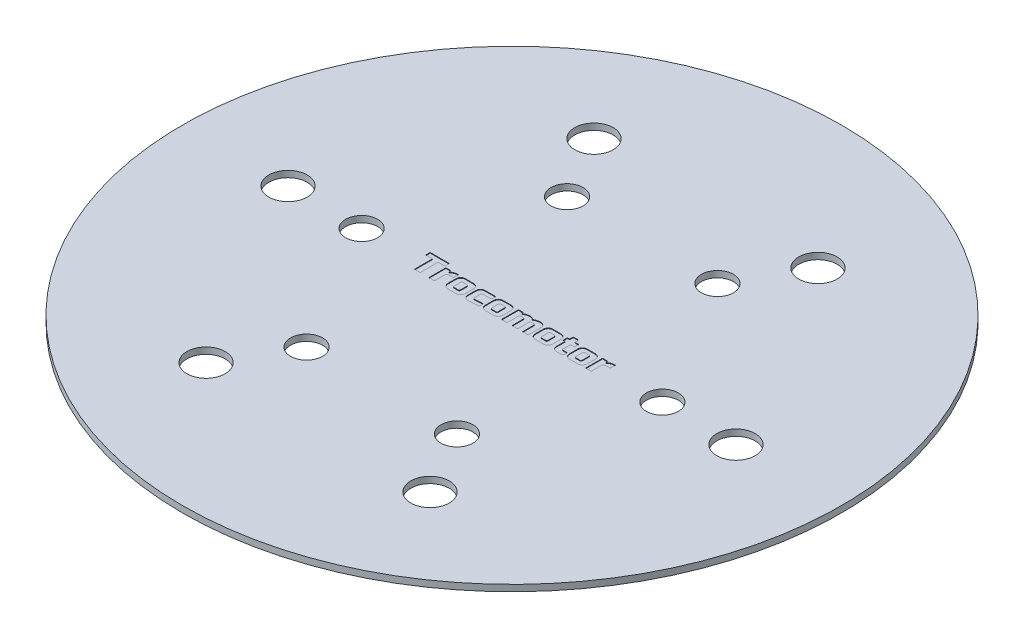
from build123d import *

# Parameters (mm, degrees)
SKETCH1_R           = 51.5
SKETCH1_R_2         = 2.5
SKETCH1_R_3         = 3
BOSS_EXTRUDE1_DEPTH = 1
CUT_EXTRUDE1_DEPTH  = 0.1


with BuildPart() as part:
    # Sketch1 → Boss-Extrude1 (new body)
    with BuildSketch(Plane(origin=(0, 0, 0), x_dir=(1, 0, 0), z_dir=(0, 1, 0))):
        Circle(SKETCH1_R)
        with Locations((23.5, 0)):
            Circle(SKETCH1_R_2, mode=Mode.SUBTRACT)
        with Locations((35, 0)):
            Circle(SKETCH1_R_3, mode=Mode.SUBTRACT)
        with Locations((11.75, -20.351596989)):
            Circle(SKETCH1_R_2, mode=Mode.SUBTRACT)
        with Locations((17.5, -30.310889132)):
            Circle(SKETCH1_R_3, mode=Mode.SUBTRACT)
        with Locations((-11.75, -20.351596989)):
            Circle(SKETCH1_R_2, mode=Mode.SUBTRACT)
        with Locations((-17.5, -30.310889132)):
            Circle(SKETCH1_R_3, mode=Mode.SUBTRACT)
        with Locations((-23.5, 0)):
            Circle(SKETCH1_R_2, mode=Mode.SUBTRACT)
        with Locations((-35, 0)):
            Circle(SKETCH1_R_3, mode=Mode.SUBTRACT)
        with Locations((-11.75, 20.351596989)):
            Circle(SKETCH1_R_2, mode=Mode.SUBTRACT)
        with Locations((-17.5, 30.310889132)):
            Circle(SKETCH1_R_3, mode=Mode.SUBTRACT)
        with Locations((11.75, 20.351596989)):
            Circle(SKETCH1_R_2, mode=Mode.SUBTRACT)
        with Locations((17.5, 30.310889132)):
            Circle(SKETCH1_R_3, mode=Mode.SUBTRACT)
    extrude(amount=BOSS_EXTRUDE1_DEPTH)

    # Sketch2 → Cut-Extrude1 (cut)
    with BuildSketch(Plane(origin=(0, 1, 0), x_dir=(1, 0, 0), z_dir=(0, 1, 0))):
        Polygon((-12.954630012, -1.385679129), (-13.854588673, -1.385679129), (-13.854588673, 1.414754934), (-14.905022737, 1.414754934), (-14.905022737, 2.114320871), (-11.904919388, 2.114320871), (-11.904919388, 1.414754934), (-12.954630012, 1.414754934), align=None)
        with BuildLine():
            add(Edge.make_bspline(
                [(-10.077511368, 0.539393215), (-10.130693873, 0.537566002), (-10.238506998, 0.533861823), (-10.400551905, 0.503611331), (-10.565590742, 0.458041721), (-10.672861917, 0.412830817), (-10.727883423, 0.389641251)],
                knots=[0, 0, 0, 0, 0.000159434, 0.00032321, 0.000493137, 0.000672078, 0.000672078, 0.000672078, 0.000672078], degree=3))
            Line((-10.727883423, 0.389641251), (-10.727883423, -1.385679129))
            Line((-10.727883423, -1.385679129), (-11.602521703, -1.385679129))
            Line((-11.602521703, -1.385679129), (-11.602521703, 1.264279531))
            Line((-11.602521703, 1.264279531), (-10.827718065, 1.264279531))
            Line((-10.827718065, 1.264279531), (-10.777800744, 0.939455224))
            add(Edge.make_bspline(
                [(-10.777800744, 0.939455224), (-10.742009923, 0.969117056), (-10.671956487, 1.027174212), (-10.562594976, 1.10431632), (-10.451388794, 1.16895906), (-10.339261666, 1.222267312), (-10.225439803, 1.262811854), (-10.110859676, 1.29300493), (-9.99463304, 1.310777818), (-9.916724856, 1.313058566), (-9.877842084, 1.314196853)],
                knots=[0, 0, 0, 0, 0.000139421, 0.000272889, 0.00040094, 0.000524887, 0.000644795, 0.000762884, 0.000879929, 0.000996547, 0.000996547, 0.000996547, 0.000996547], degree=3))
            Line((-9.877842084, 1.314196853), (-9.652852418, 1.314196853))
            Line((-9.652852418, 1.314196853), (-9.652852418, 0.539393215))
            Line((-9.652852418, 0.539393215), (-10.077511368, 0.539393215))
        make_face()
        with BuildLine():
            add(Edge.make_bspline(
                [(-6.58763952, -0.635472432), (-6.58843321, -0.665877006), (-6.589980361, -0.725145132), (-6.599153994, -0.811881154), (-6.61580641, -0.893446584), (-6.63871088, -0.970256817), (-6.669577439, -1.041183123), (-6.705555384, -1.107879516), (-6.749405662, -1.168803852), (-6.79939127, -1.224546338), (-6.854906859, -1.274692216), (-6.916543144, -1.317411521), (-6.982193464, -1.354548413), (-7.053568604, -1.384585808), (-7.1300668, -1.407243854), (-7.211578231, -1.424176329), (-7.29809406, -1.433236808), (-7.357360057, -1.434796386), (-7.387763539, -1.43559645)],
                knots=[0, 0, 0, 0, 9.1225e-05, 0.000177827, 0.000261251, 0.000340662, 0.000417796, 0.000492911, 0.000567591, 0.000642389, 0.000717187, 0.000791448, 0.000866915, 0.0009431, 0.001023202, 0.001105918, 0.00119252, 0.001283745, 0.001283745, 0.001283745, 0.001283745], degree=3))
            Line((-7.387763539, -1.43559645), (-8.538032245, -1.43559645))
            add(Edge.make_bspline(
                [(-8.538032245, -1.43559645), (-8.56843671, -1.434799347), (-8.627704625, -1.433245542), (-8.714206834, -1.424144063), (-8.795540349, -1.407404064), (-8.87186707, -1.384263502), (-8.943449151, -1.354759941), (-9.009241677, -1.317384773), (-9.070893172, -1.274699913), (-9.126398446, -1.224542302), (-9.176410106, -1.168812264), (-9.22016647, -1.10784988), (-9.256453857, -1.041377969), (-9.285953016, -0.969931033), (-9.310293942, -0.893622824), (-9.326551561, -0.811851075), (-9.33583976, -0.725153246), (-9.337370826, -0.665879757), (-9.338156263, -0.635472432)],
                knots=[0, 0, 0, 0, 9.1225e-05, 0.000177827, 0.000260543, 0.000339953, 0.000416805, 0.000492272, 0.000566533, 0.000641331, 0.000716129, 0.000790808, 0.000865924, 0.000942776, 0.0010224, 0.001105825, 0.001192426, 0.001283651, 0.001283651, 0.001283651, 0.001283651], degree=3))
            Line((-9.338156263, -0.635472432), (-9.338156263, 0.514796274))
            add(Edge.make_bspline(
                [(-9.338156263, 0.514796274), (-9.337365444, 0.545202603), (-9.335823889, 0.604474152), (-9.326635397, 0.69095055), (-9.310190014, 0.772445675), (-9.285929432, 0.84851499), (-9.256652947, 0.919848221), (-9.219942445, 0.98584621), (-9.176426145, 1.046686616), (-9.126435307, 1.102482477), (-9.070626124, 1.152420534), (-9.009719825, 1.196284414), (-8.943017884, 1.232255387), (-8.872095684, 1.263136614), (-8.795501113, 1.285919479), (-8.714218017, 1.302768687), (-8.627701598, 1.311839388), (-8.568435683, 1.313397527), (-8.538032245, 1.314196853)],
                knots=[0, 0, 0, 0, 9.1225e-05, 0.000177827, 0.000260543, 0.000340167, 0.000417019, 0.000491501, 0.00056618, 0.000640979, 0.000715777, 0.000790456, 0.000865572, 0.000942705, 0.001022116, 0.001104832, 0.001191433, 0.001282659, 0.001282659, 0.001282659, 0.001282659], degree=3))
            Line((-8.538032245, 1.314196853), (-7.387763539, 1.314196853))
            add(Edge.make_bspline(
                [(-7.387763539, 1.314196853), (-7.357361097, 1.313394553), (-7.298097126, 1.311830616), (-7.211566904, 1.302801096), (-7.130106685, 1.285758462), (-7.053336365, 1.263462871), (-6.982625101, 1.232046402), (-6.916064377, 1.196311943), (-6.855174078, 1.152412636), (-6.799354363, 1.102486563), (-6.749389652, 1.046678183), (-6.705779604, 0.985875776), (-6.669375331, 0.919654656), (-6.638733759, 0.848841037), (-6.615907263, 0.772270432), (-6.599070431, 0.690980538), (-6.589996242, 0.604466035), (-6.588438594, 0.545199851), (-6.58763952, 0.514796274)],
                knots=[0, 0, 0, 0, 9.1225e-05, 0.000177827, 0.000260543, 0.000340645, 0.000417115, 0.000492231, 0.00056691, 0.000641708, 0.000716506, 0.000791185, 0.000865668, 0.000942802, 0.001022212, 0.001104928, 0.00119153, 0.001282755, 0.001282755, 0.001282755, 0.001282755], degree=3))
            Line((-6.58763952, 0.514796274), (-6.58763952, -0.635472432))
        make_face()
        with BuildLine():
            add(Edge.make_bspline(
                [(-7.46300124, 0.439558572), (-7.463429228, 0.455280053), (-7.464235033, 0.484880114), (-7.473503581, 0.526297296), (-7.489794119, 0.561151975), (-7.511693524, 0.590535573), (-7.541077123, 0.612434979), (-7.575931801, 0.628725516), (-7.617348984, 0.637994065), (-7.646949044, 0.63879987), (-7.662670525, 0.639227857)],
                knots=[0, 0, 0, 0, 4.7113e-05, 8.8702e-05, 0.000126245, 0.000161841, 0.000197436, 0.000234979, 0.000276569, 0.000323681, 0.000323681, 0.000323681, 0.000323681], degree=3))
            Line((-7.662670525, 0.639227857), (-8.262401819, 0.639227857))
            add(Edge.make_bspline(
                [(-8.262401819, 0.639227857), (-8.278129265, 0.638812972), (-8.307740558, 0.638031836), (-8.349298406, 0.628551044), (-8.384578016, 0.612647939), (-8.414092727, 0.590514628), (-8.436004364, 0.561157906), (-8.452291381, 0.52629549), (-8.461560998, 0.484880658), (-8.462366642, 0.455280242), (-8.462794543, 0.439558572)],
                knots=[0, 0, 0, 0, 4.7113e-05, 8.8702e-05, 0.000126901, 0.000162497, 0.000198093, 0.000235635, 0.000277225, 0.000324338, 0.000324338, 0.000324338, 0.000324338], degree=3))
            Line((-8.462794543, 0.439558572), (-8.462794543, -0.56095817))
            add(Edge.make_bspline(
                [(-8.462794543, -0.56095817), (-8.462366642, -0.576679839), (-8.461560998, -0.606280255), (-8.452291381, -0.647695088), (-8.436004364, -0.682557504), (-8.414092727, -0.711914226), (-8.384578016, -0.734047536), (-8.349298406, -0.749950642), (-8.307740558, -0.759431433), (-8.278129265, -0.76021257), (-8.262401819, -0.760627455)],
                knots=[0, 0, 0, 0, 4.7113e-05, 8.8702e-05, 0.000126245, 0.000161841, 0.000197436, 0.000235635, 0.000277225, 0.000324338, 0.000324338, 0.000324338, 0.000324338], degree=3))
            Line((-8.262401819, -0.760627455), (-7.662670525, -0.760627455))
            add(Edge.make_bspline(
                [(-7.662670525, -0.760627455), (-7.646949044, -0.760199468), (-7.617348984, -0.759393662), (-7.575931801, -0.750125114), (-7.541077123, -0.733834577), (-7.511693524, -0.711935171), (-7.489794119, -0.682551572), (-7.473503581, -0.647696894), (-7.464235033, -0.606279712), (-7.463429228, -0.576679651), (-7.46300124, -0.56095817)],
                knots=[0, 0, 0, 0, 4.7113e-05, 8.8702e-05, 0.000126245, 0.000161841, 0.000197436, 0.000234979, 0.000276569, 0.000323681, 0.000323681, 0.000323681, 0.000323681], degree=3))
            Line((-7.46300124, -0.56095817), (-7.46300124, 0.439558572))
        make_face(mode=Mode.SUBTRACT)
        with BuildLine():
            add(Edge.make_bspline(
                [(-3.789375775, -1.335761808), (-3.866044014, -1.343648372), (-4.01713998, -1.359191026), (-4.24047292, -1.379213492), (-4.456983717, -1.397085946), (-4.66686896, -1.410148179), (-4.869844696, -1.422725584), (-5.065983898, -1.429028655), (-5.255028702, -1.434982607), (-5.37876737, -1.435394266), (-5.439541133, -1.43559645)],
                knots=[0, 0, 0, 0, 0.000231216, 0.000455674, 0.000672678, 0.000882926, 0.001086541, 0.001282727, 0.001471612, 0.001653925, 0.001653925, 0.001653925, 0.001653925], degree=3))
            add(Edge.make_bspline(
                [(-5.439541133, -1.43559645), (-5.467313429, -1.435223467), (-5.521369864, -1.434497486), (-5.600170365, -1.423544274), (-5.674895653, -1.408175024), (-5.745648205, -1.385492014), (-5.8120532, -1.356668419), (-5.874640406, -1.32163434), (-5.932209609, -1.279389197), (-5.986086013, -1.231934634), (-6.033540576, -1.17805823), (-6.075785719, -1.120489027), (-6.110819798, -1.057901821), (-6.139643393, -0.991496826), (-6.162326403, -0.920744273), (-6.177695653, -0.846018986), (-6.188648865, -0.767218485), (-6.189374846, -0.71316205), (-6.18974783, -0.685389753)],
                knots=[0, 0, 0, 0, 8.3246e-05, 0.000162031, 0.000238226, 0.000311896, 0.000384471, 0.000455091, 0.000526576, 0.00059831, 0.000670044, 0.000741529, 0.000812148, 0.000884723, 0.000958394, 0.001034589, 0.001113374, 0.00119662, 0.00119662, 0.00119662, 0.00119662], degree=3))
            Line((-6.18974783, -0.685389753), (-6.18974783, 0.464155513))
            add(Edge.make_bspline(
                [(-6.18974783, 0.464155513), (-6.188953739, 0.494560682), (-6.187405804, 0.55382997), (-6.178262621, 0.640322431), (-6.161610275, 0.721986382), (-6.137882012, 0.798256021), (-6.107832642, 0.869490303), (-6.071789052, 0.935825372), (-6.027982366, 0.996750953), (-5.978036351, 1.052570074), (-5.922215157, 1.102501898), (-5.861312074, 1.146367447), (-5.794609262, 1.182337968), (-5.723687304, 1.21321932), (-5.647092664, 1.23600215), (-5.565809588, 1.252851368), (-5.479293164, 1.261922066), (-5.42002725, 1.263480205), (-5.389623811, 1.264279531)],
                knots=[0, 0, 0, 0, 9.1225e-05, 0.000177827, 0.000260543, 0.000340857, 0.000417042, 0.000492158, 0.000566837, 0.000641635, 0.000716434, 0.000791113, 0.000866229, 0.000943362, 0.001022773, 0.001105489, 0.00119209, 0.001283315, 0.001283315, 0.001283315, 0.001283315], degree=3))
            Line((-5.389623811, 1.264279531), (-3.789375775, 1.264279531))
            Line((-3.789375775, 1.264279531), (-3.789375775, 0.589310536))
            Line((-3.789375775, 0.589310536), (-5.113993386, 0.589310536))
            add(Edge.make_bspline(
                [(-5.113993386, 0.589310536), (-5.129720832, 0.588895651), (-5.159332125, 0.588114514), (-5.200889973, 0.578633723), (-5.236169583, 0.562730617), (-5.265684294, 0.540597307), (-5.287595931, 0.511240585), (-5.303882948, 0.476378169), (-5.313152565, 0.434963336), (-5.313958208, 0.40536292), (-5.31438611, 0.389641251)],
                knots=[0, 0, 0, 0, 4.7113e-05, 8.8702e-05, 0.000126901, 0.000162497, 0.000198093, 0.000235635, 0.000277225, 0.000324338, 0.000324338, 0.000324338, 0.000324338], degree=3))
            Line((-5.31438611, 0.389641251), (-5.31438611, -0.585555111))
            add(Edge.make_bspline(
                [(-5.31438611, -0.585555111), (-5.313937086, -0.597679225), (-5.313068753, -0.621125074), (-5.30322528, -0.654708837), (-5.286856237, -0.684703361), (-5.265384233, -0.711625578), (-5.238462016, -0.733097582), (-5.208467492, -0.749466625), (-5.174883729, -0.759310098), (-5.15143788, -0.760178431), (-5.139313766, -0.760627455)],
                knots=[0, 0, 0, 0, 3.6288e-05, 7.0174e-05, 0.000103835, 0.000138295, 0.000172756, 0.000206417, 0.000240303, 0.00027659, 0.00027659, 0.00027659, 0.00027659], degree=3))
            add(Edge.make_bspline(
                [(-5.139313766, -0.760627455), (-5.099522518, -0.760268298), (-5.015103827, -0.759506333), (-4.881498927, -0.755667698), (-4.733674522, -0.749769579), (-4.572071377, -0.742029515), (-4.396307581, -0.730747546), (-4.206516125, -0.71782947), (-4.002503891, -0.702611217), (-3.861954759, -0.691254378), (-3.789375775, -0.685389753)],
                knots=[0, 0, 0, 0, 0.000119376, 0.000253261, 0.000400957, 0.000563202, 0.000738611, 0.00092932, 0.001133895, 0.001352341, 0.001352341, 0.001352341, 0.001352341], degree=3))
            Line((-3.789375775, -0.685389753), (-3.789375775, -1.335761808))
        make_face()
        with BuildLine():
            add(Edge.make_bspline(
                [(-0.70752377, -0.635472432), (-0.708317459, -0.665877006), (-0.709864611, -0.725145132), (-0.719038244, -0.811881154), (-0.735690659, -0.893446584), (-0.75859513, -0.970256817), (-0.789461689, -1.041183123), (-0.825439634, -1.107879516), (-0.869289912, -1.168803852), (-0.919275519, -1.224546338), (-0.974791109, -1.274692216), (-1.036427394, -1.317411521), (-1.102077713, -1.354548413), (-1.173452853, -1.384585808), (-1.24995105, -1.407243854), (-1.33146248, -1.424176329), (-1.417978309, -1.433236808), (-1.477244307, -1.434796386), (-1.507647788, -1.43559645)],
                knots=[0, 0, 0, 0, 9.1225e-05, 0.000177827, 0.000261251, 0.000340662, 0.000417796, 0.000492911, 0.000567591, 0.000642389, 0.000717187, 0.000791448, 0.000866915, 0.0009431, 0.001023202, 0.001105918, 0.00119252, 0.001283745, 0.001283745, 0.001283745, 0.001283745], degree=3))
            Line((-1.507647788, -1.43559645), (-2.657916494, -1.43559645))
            add(Edge.make_bspline(
                [(-2.657916494, -1.43559645), (-2.688320959, -1.434799347), (-2.747588875, -1.433245542), (-2.834091083, -1.424144063), (-2.915424599, -1.407404064), (-2.991751319, -1.384263502), (-3.0633334, -1.354759941), (-3.129125926, -1.317384773), (-3.190777421, -1.274699913), (-3.246282696, -1.224542302), (-3.296294356, -1.168812264), (-3.34005072, -1.10784988), (-3.376338107, -1.041377969), (-3.405837266, -0.969931033), (-3.430178191, -0.893622824), (-3.446435811, -0.811851075), (-3.455724009, -0.725153246), (-3.457255075, -0.665879757), (-3.458040513, -0.635472432)],
                knots=[0, 0, 0, 0, 9.1225e-05, 0.000177827, 0.000260543, 0.000339953, 0.000416805, 0.000492272, 0.000566533, 0.000641331, 0.000716129, 0.000790808, 0.000865924, 0.000942776, 0.0010224, 0.001105825, 0.001192426, 0.001283651, 0.001283651, 0.001283651, 0.001283651], degree=3))
            Line((-3.458040513, -0.635472432), (-3.458040513, 0.514796274))
            add(Edge.make_bspline(
                [(-3.458040513, 0.514796274), (-3.457249694, 0.545202603), (-3.455708138, 0.604474152), (-3.446519647, 0.69095055), (-3.430074264, 0.772445675), (-3.405813682, 0.84851499), (-3.376537196, 0.919848221), (-3.339826695, 0.98584621), (-3.296310395, 1.046686616), (-3.246319557, 1.102482477), (-3.190510374, 1.152420534), (-3.129604074, 1.196284414), (-3.062902134, 1.232255387), (-2.991979934, 1.263136614), (-2.915385362, 1.285919479), (-2.834102266, 1.302768687), (-2.747585848, 1.311839388), (-2.688319933, 1.313397527), (-2.657916494, 1.314196853)],
                knots=[0, 0, 0, 0, 9.1225e-05, 0.000177827, 0.000260543, 0.000340167, 0.000417019, 0.000491501, 0.00056618, 0.000640979, 0.000715777, 0.000790456, 0.000865572, 0.000942705, 0.001022116, 0.001104832, 0.001191433, 0.001282659, 0.001282659, 0.001282659, 0.001282659], degree=3))
            Line((-2.657916494, 1.314196853), (-1.507647788, 1.314196853))
            add(Edge.make_bspline(
                [(-1.507647788, 1.314196853), (-1.477245347, 1.313394553), (-1.417981375, 1.311830616), (-1.331451153, 1.302801096), (-1.249990935, 1.285758462), (-1.173220614, 1.263462871), (-1.102509351, 1.232046402), (-1.035948627, 1.196311943), (-0.975058327, 1.152412636), (-0.919238613, 1.102486563), (-0.869273902, 1.046678183), (-0.825663854, 0.985875776), (-0.78925958, 0.919654656), (-0.758618008, 0.848841037), (-0.735791513, 0.772270432), (-0.718954681, 0.690980538), (-0.709880492, 0.604466035), (-0.708322844, 0.545199851), (-0.70752377, 0.514796274)],
                knots=[0, 0, 0, 0, 9.1225e-05, 0.000177827, 0.000260543, 0.000340645, 0.000417115, 0.000492231, 0.00056691, 0.000641708, 0.000716506, 0.000791185, 0.000865668, 0.000942802, 0.001022212, 0.001104928, 0.00119153, 0.001282755, 0.001282755, 0.001282755, 0.001282755], degree=3))
            Line((-0.70752377, 0.514796274), (-0.70752377, -0.635472432))
        make_face()
        with BuildLine():
            add(Edge.make_bspline(
                [(-1.58288549, 0.439558572), (-1.583313477, 0.455280053), (-1.584119282, 0.484880114), (-1.593387831, 0.526297296), (-1.609678368, 0.561151975), (-1.631577774, 0.590535573), (-1.660961373, 0.612434979), (-1.695816051, 0.628725516), (-1.737233233, 0.637994065), (-1.766833294, 0.63879987), (-1.782554775, 0.639227857)],
                knots=[0, 0, 0, 0, 4.7113e-05, 8.8702e-05, 0.000126245, 0.000161841, 0.000197436, 0.000234979, 0.000276569, 0.000323681, 0.000323681, 0.000323681, 0.000323681], degree=3))
            Line((-1.782554775, 0.639227857), (-2.382286069, 0.639227857))
            add(Edge.make_bspline(
                [(-2.382286069, 0.639227857), (-2.398013515, 0.638812972), (-2.427624808, 0.638031836), (-2.469182655, 0.628551044), (-2.504462266, 0.612647939), (-2.533976977, 0.590514628), (-2.555888614, 0.561157906), (-2.57217563, 0.52629549), (-2.581445248, 0.484880658), (-2.582250891, 0.455280242), (-2.582678793, 0.439558572)],
                knots=[0, 0, 0, 0, 4.7113e-05, 8.8702e-05, 0.000126901, 0.000162497, 0.000198093, 0.000235635, 0.000277225, 0.000324338, 0.000324338, 0.000324338, 0.000324338], degree=3))
            Line((-2.582678793, 0.439558572), (-2.582678793, -0.56095817))
            add(Edge.make_bspline(
                [(-2.582678793, -0.56095817), (-2.582250891, -0.576679839), (-2.581445248, -0.606280255), (-2.57217563, -0.647695088), (-2.555888614, -0.682557504), (-2.533976977, -0.711914226), (-2.504462266, -0.734047536), (-2.469182655, -0.749950642), (-2.427624808, -0.759431433), (-2.398013515, -0.76021257), (-2.382286069, -0.760627455)],
                knots=[0, 0, 0, 0, 4.7113e-05, 8.8702e-05, 0.000126245, 0.000161841, 0.000197436, 0.000235635, 0.000277225, 0.000324338, 0.000324338, 0.000324338, 0.000324338], degree=3))
            Line((-2.382286069, -0.760627455), (-1.782554775, -0.760627455))
            add(Edge.make_bspline(
                [(-1.782554775, -0.760627455), (-1.766833294, -0.760199468), (-1.737233233, -0.759393662), (-1.695816051, -0.750125114), (-1.660961373, -0.733834577), (-1.631577774, -0.711935171), (-1.609678368, -0.682551572), (-1.593387831, -0.647696894), (-1.584119282, -0.606279712), (-1.583313477, -0.576679651), (-1.58288549, -0.56095817)],
                knots=[0, 0, 0, 0, 4.7113e-05, 8.8702e-05, 0.000126245, 0.000161841, 0.000197436, 0.000234979, 0.000276569, 0.000323681, 0.000323681, 0.000323681, 0.000323681], degree=3))
            Line((-1.58288549, -0.56095817), (-1.58288549, 0.439558572))
        make_face(mode=Mode.SUBTRACT)
        with BuildLine():
            add(Edge.make_bspline(
                [(1.515605622, 1.314196853), (1.548464751, 1.313548649), (1.612594943, 1.312283569), (1.70564259, 1.297034486), (1.79315039, 1.27425156), (1.875084969, 1.241649507), (1.950557238, 1.198409381), (2.020665339, 1.146678394), (2.085100469, 1.085591327), (2.121935924, 1.038584055), (2.140657296, 1.014692925)],
                knots=[0, 0, 0, 0, 9.8483e-05, 0.000192207, 0.000282054, 0.000369374, 0.000455876, 0.000542257, 0.000630267, 0.000721228, 0.000721228, 0.000721228, 0.000721228], degree=3))
            add(Edge.make_bspline(
                [(2.140657296, 1.014692925), (2.179322356, 1.039491577), (2.256499084, 1.088990501), (2.379200365, 1.150850937), (2.506465354, 1.202671569), (2.636783945, 1.242765959), (2.765384574, 1.274359167), (2.888621206, 1.296698473), (3.004559339, 1.311623553), (3.079640397, 1.313359545), (3.115853659, 1.314196853)],
                knots=[0, 0, 0, 0, 0.000137727, 0.000274908, 0.000411533, 0.000549505, 0.000683558, 0.000808571, 0.000925135, 0.001033738, 0.001033738, 0.001033738, 0.001033738], degree=3))
            Line((3.115853659, 1.314196853), (3.16577098, 1.314196853))
            add(Edge.make_bspline(
                [(3.16577098, 1.314196853), (3.193542764, 1.3138228), (3.247598203, 1.313094738), (3.326405793, 1.302156333), (3.401105582, 1.286733825), (3.471738199, 1.264308279), (3.53781685, 1.23483385), (3.600683217, 1.200705634), (3.657799845, 1.157742815), (3.71157139, 1.110320715), (3.759660781, 1.057210273), (3.801505395, 0.999149023), (3.836818609, 0.937019016), (3.866019634, 0.870639157), (3.888534141, 0.800059886), (3.903931696, 0.725345133), (3.914877038, 0.646541704), (3.915604125, 0.59248568), (3.915977677, 0.564713595)],
                knots=[0, 0, 0, 0, 8.3246e-05, 0.000162031, 0.000238226, 0.000311896, 0.000383808, 0.000455059, 0.00052596, 0.000597693, 0.000669911, 0.000740386, 0.000811992, 0.000883904, 0.000957574, 0.001033769, 0.001112554, 0.0011958, 0.0011958, 0.0011958, 0.0011958], degree=3))
            Line((3.915977677, 0.564713595), (3.915977677, -1.385679129))
            Line((3.915977677, -1.385679129), (3.041339396, -1.385679129))
            Line((3.041339396, -1.385679129), (3.041339396, 0.414238192))
            add(Edge.make_bspline(
                [(3.041339396, 0.414238192), (3.040893826, 0.42636505), (3.040032172, 0.449816205), (3.030141248, 0.483362267), (3.013877102, 0.513634107), (2.991586224, 0.540108005), (2.964841329, 0.56156505), (2.935080186, 0.578489015), (2.901542504, 0.587800863), (2.878135078, 0.588802624), (2.866267053, 0.589310536)],
                knots=[0, 0, 0, 0, 3.6288e-05, 7.0174e-05, 0.000103835, 0.000138755, 0.000173216, 0.000206241, 0.000240823, 0.000276389, 0.000276389, 0.000276389, 0.000276389], degree=3))
            Line((2.866267053, 0.589310536), (2.840946672, 0.589310536))
            add(Edge.make_bspline(
                [(2.840946672, 0.589310536), (2.800868528, 0.587763105), (2.715068266, 0.584450326), (2.578595831, 0.565412916), (2.426930362, 0.532901725), (2.321389418, 0.50445548), (2.265812319, 0.489475894)],
                knots=[0, 0, 0, 0, 0.000120267, 0.000257471, 0.000412692, 0.000585352, 0.000585352, 0.000585352, 0.000585352], degree=3))
            Line((2.265812319, 0.489475894), (2.265812319, -1.385679129))
            Line((2.265812319, -1.385679129), (1.391174039, -1.385679129))
            Line((1.391174039, -1.385679129), (1.391174039, 0.414238192))
            add(Edge.make_bspline(
                [(1.391174039, 0.414238192), (1.390728468, 0.42636505), (1.389866815, 0.449816205), (1.379975891, 0.483362267), (1.363711745, 0.513634107), (1.341420867, 0.540108005), (1.314675971, 0.56156505), (1.284914829, 0.578489015), (1.251377146, 0.587800863), (1.22796972, 0.588802624), (1.216101695, 0.589310536)],
                knots=[0, 0, 0, 0, 3.6288e-05, 7.0174e-05, 0.000103835, 0.000138755, 0.000173216, 0.000206241, 0.000240823, 0.000276389, 0.000276389, 0.000276389, 0.000276389], degree=3))
            Line((1.216101695, 0.589310536), (1.190781315, 0.589310536))
            add(Edge.make_bspline(
                [(1.190781315, 0.589310536), (1.15070317, 0.587763105), (1.064902908, 0.584450326), (0.928430474, 0.565412916), (0.776765004, 0.532901725), (0.67122406, 0.50445548), (0.615646962, 0.489475894)],
                knots=[0, 0, 0, 0, 0.000120267, 0.000257471, 0.000412692, 0.000585352, 0.000585352, 0.000585352, 0.000585352], degree=3))
            Line((0.615646962, 0.489475894), (0.615646962, -1.385679129))
            Line((0.615646962, -1.385679129), (-0.258991319, -1.385679129))
            Line((-0.258991319, -1.385679129), (-0.258991319, 1.264279531))
            Line((-0.258991319, 1.264279531), (0.515812319, 1.264279531))
            Line((0.515812319, 1.264279531), (0.56572964, 1.014692925))
            add(Edge.make_bspline(
                [(0.56572964, 1.014692925), (0.604957911, 1.039349273), (0.682185809, 1.087889722), (0.802172653, 1.150505671), (0.923975006, 1.201992828), (1.045730905, 1.242323386), (1.162964417, 1.274000117), (1.272428652, 1.296387495), (1.372188511, 1.311441521), (1.435740472, 1.313314325), (1.465688301, 1.314196853)],
                knots=[0, 0, 0, 0, 0.000138961, 0.000273569, 0.000405515, 0.000535229, 0.000658069, 0.000769586, 0.000870363, 0.000960174, 0.000960174, 0.000960174, 0.000960174], degree=3))
            Line((1.465688301, 1.314196853), (1.515605622, 1.314196853))
        make_face()
        with BuildLine():
            add(Edge.make_bspline(
                [(7.070897065, -0.635472432), (7.070103376, -0.665877006), (7.068556224, -0.725145132), (7.059382591, -0.811881154), (7.042730176, -0.893446584), (7.019825705, -0.970256817), (6.988959146, -1.041183123), (6.952981201, -1.107879516), (6.909130923, -1.168803852), (6.859145316, -1.224546338), (6.803629726, -1.274692216), (6.741993441, -1.317411521), (6.676343122, -1.354548413), (6.604967982, -1.384585808), (6.528469785, -1.407243854), (6.446958355, -1.424176329), (6.360442526, -1.433236808), (6.301176528, -1.434796386), (6.270773047, -1.43559645)],
                knots=[0, 0, 0, 0, 9.1225e-05, 0.000177827, 0.000261251, 0.000340662, 0.000417796, 0.000492911, 0.000567591, 0.000642389, 0.000717187, 0.000791448, 0.000866915, 0.0009431, 0.001023202, 0.001105918, 0.00119252, 0.001283745, 0.001283745, 0.001283745, 0.001283745], degree=3))
            Line((6.270773047, -1.43559645), (5.120504341, -1.43559645))
            add(Edge.make_bspline(
                [(5.120504341, -1.43559645), (5.090099876, -1.434799347), (5.030831961, -1.433245542), (4.944329752, -1.424144063), (4.862996236, -1.407404064), (4.786669516, -1.384263502), (4.715087435, -1.354759941), (4.649294909, -1.317384773), (4.587643414, -1.274699913), (4.532138139, -1.224542302), (4.482126479, -1.168812264), (4.438370115, -1.10784988), (4.402082728, -1.041377969), (4.372583569, -0.969931033), (4.348242644, -0.893622824), (4.331985024, -0.811851075), (4.322696826, -0.725153246), (4.32116576, -0.665879757), (4.320380322, -0.635472432)],
                knots=[0, 0, 0, 0, 9.1225e-05, 0.000177827, 0.000260543, 0.000339953, 0.000416805, 0.000492272, 0.000566533, 0.000641331, 0.000716129, 0.000790808, 0.000865924, 0.000942776, 0.0010224, 0.001105825, 0.001192426, 0.001283651, 0.001283651, 0.001283651, 0.001283651], degree=3))
            Line((4.320380322, -0.635472432), (4.320380322, 0.514796274))
            add(Edge.make_bspline(
                [(4.320380322, 0.514796274), (4.321171141, 0.545202603), (4.322712697, 0.604474152), (4.331901188, 0.69095055), (4.348346571, 0.772445675), (4.372607154, 0.84851499), (4.401883639, 0.919848221), (4.438594141, 0.98584621), (4.48211044, 1.046686616), (4.532101278, 1.102482477), (4.587910461, 1.152420534), (4.648816761, 1.196284414), (4.715518702, 1.232255387), (4.786440901, 1.263136614), (4.863035473, 1.285919479), (4.944318569, 1.302768687), (5.030834987, 1.311839388), (5.090100902, 1.313397527), (5.120504341, 1.314196853)],
                knots=[0, 0, 0, 0, 9.1225e-05, 0.000177827, 0.000260543, 0.000340167, 0.000417019, 0.000491501, 0.00056618, 0.000640979, 0.000715777, 0.000790456, 0.000865572, 0.000942705, 0.001022116, 0.001104832, 0.001191433, 0.001282659, 0.001282659, 0.001282659, 0.001282659], degree=3))
            Line((5.120504341, 1.314196853), (6.270773047, 1.314196853))
            add(Edge.make_bspline(
                [(6.270773047, 1.314196853), (6.301175489, 1.313394553), (6.36043946, 1.311830616), (6.446969682, 1.302801096), (6.5284299, 1.285758462), (6.605200221, 1.263462871), (6.675911484, 1.232046402), (6.742472208, 1.196311943), (6.803362508, 1.152412636), (6.859182222, 1.102486563), (6.909146933, 1.046678183), (6.952756981, 0.985875776), (6.989161255, 0.919654656), (7.019802827, 0.848841037), (7.042629322, 0.772270432), (7.059466154, 0.690980538), (7.068540343, 0.604466035), (7.070097991, 0.545199851), (7.070897065, 0.514796274)],
                knots=[0, 0, 0, 0, 9.1225e-05, 0.000177827, 0.000260543, 0.000340645, 0.000417115, 0.000492231, 0.00056691, 0.000641708, 0.000716506, 0.000791185, 0.000865668, 0.000942802, 0.001022212, 0.001104928, 0.00119153, 0.001282755, 0.001282755, 0.001282755, 0.001282755], degree=3))
            Line((7.070897065, 0.514796274), (7.070897065, -0.635472432))
        make_face()
        with BuildLine():
            add(Edge.make_bspline(
                [(6.195535345, 0.439558572), (6.195107358, 0.455280053), (6.194301553, 0.484880114), (6.185033004, 0.526297296), (6.168742467, 0.561151975), (6.146843061, 0.590535573), (6.117459463, 0.612434979), (6.082604784, 0.628725516), (6.041187602, 0.637994065), (6.011587541, 0.63879987), (5.99586606, 0.639227857)],
                knots=[0, 0, 0, 0, 4.7113e-05, 8.8702e-05, 0.000126245, 0.000161841, 0.000197436, 0.000234979, 0.000276569, 0.000323681, 0.000323681, 0.000323681, 0.000323681], degree=3))
            Line((5.99586606, 0.639227857), (5.396134766, 0.639227857))
            add(Edge.make_bspline(
                [(5.396134766, 0.639227857), (5.38040732, 0.638812972), (5.350796027, 0.638031836), (5.30923818, 0.628551044), (5.273958569, 0.612647939), (5.244443858, 0.590514628), (5.222532221, 0.561157906), (5.206245205, 0.52629549), (5.196975587, 0.484880658), (5.196169944, 0.455280242), (5.195742042, 0.439558572)],
                knots=[0, 0, 0, 0, 4.7113e-05, 8.8702e-05, 0.000126901, 0.000162497, 0.000198093, 0.000235635, 0.000277225, 0.000324338, 0.000324338, 0.000324338, 0.000324338], degree=3))
            Line((5.195742042, 0.439558572), (5.195742042, -0.56095817))
            add(Edge.make_bspline(
                [(5.195742042, -0.56095817), (5.196169944, -0.576679839), (5.196975587, -0.606280255), (5.206245205, -0.647695088), (5.222532221, -0.682557504), (5.244443858, -0.711914226), (5.273958569, -0.734047536), (5.30923818, -0.749950642), (5.350796027, -0.759431433), (5.38040732, -0.76021257), (5.396134766, -0.760627455)],
                knots=[0, 0, 0, 0, 4.7113e-05, 8.8702e-05, 0.000126245, 0.000161841, 0.000197436, 0.000235635, 0.000277225, 0.000324338, 0.000324338, 0.000324338, 0.000324338], degree=3))
            Line((5.396134766, -0.760627455), (5.99586606, -0.760627455))
            add(Edge.make_bspline(
                [(5.99586606, -0.760627455), (6.011587541, -0.760199468), (6.041187602, -0.759393662), (6.082604784, -0.750125114), (6.117459463, -0.733834577), (6.146843061, -0.711935171), (6.168742467, -0.682551572), (6.185033004, -0.647696894), (6.194301553, -0.606279712), (6.195107358, -0.576679651), (6.195535345, -0.56095817)],
                knots=[0, 0, 0, 0, 4.7113e-05, 8.8702e-05, 0.000126245, 0.000161841, 0.000197436, 0.000234979, 0.000276569, 0.000323681, 0.000323681, 0.000323681, 0.000323681], degree=3))
            Line((6.195535345, -0.56095817), (6.195535345, 0.439558572))
        make_face(mode=Mode.SUBTRACT)
        with BuildLine():
            add(Edge.make_bspline(
                [(9.369264159, -1.385679129), (9.288994618, -1.393301516), (9.12932368, -1.40846385), (8.89051446, -1.424214976), (8.654108328, -1.434049539), (8.497287911, -1.435083056), (8.419388177, -1.43559645)],
                knots=[0, 0, 0, 0, 0.000241881, 0.000481146, 0.000717897, 0.000951586, 0.000951586, 0.000951586, 0.000951586], degree=3))
            add(Edge.make_bspline(
                [(8.419388177, -1.43559645), (8.39161588, -1.435223467), (8.337559445, -1.434497486), (8.258758945, -1.423544274), (8.184033657, -1.408175024), (8.113281104, -1.385492014), (8.046876109, -1.356668419), (7.984288903, -1.32163434), (7.9267197, -1.279389197), (7.872843297, -1.231934634), (7.825388734, -1.17805823), (7.783143591, -1.120489027), (7.748109511, -1.057901821), (7.719285916, -0.991496826), (7.696602907, -0.920744273), (7.681233657, -0.846018986), (7.670280444, -0.767218485), (7.669554463, -0.71316205), (7.66918148, -0.685389753)],
                knots=[0, 0, 0, 0, 8.3246e-05, 0.000162031, 0.000238226, 0.000311896, 0.000384471, 0.000455091, 0.000526576, 0.00059831, 0.000670044, 0.000741529, 0.000812148, 0.000884723, 0.000958394, 0.001034589, 0.001113374, 0.00119662, 0.00119662, 0.00119662, 0.00119662], degree=3))
            Line((7.66918148, -0.685389753), (7.66918148, 0.589310536))
            Line((7.66918148, 0.589310536), (7.368954113, 0.589310536))
            Line((7.368954113, 0.589310536), (7.368954113, 1.264279531))
            Line((7.368954113, 1.264279531), (7.66918148, 1.264279531))
            Line((7.66918148, 1.264279531), (7.769016122, 1.864734265))
            Line((7.769016122, 1.864734265), (8.5445432, 1.864734265))
            Line((8.5445432, 1.864734265), (8.5445432, 1.264279531))
            Line((8.5445432, 1.264279531), (9.169594874, 1.264279531))
            Line((9.169594874, 1.264279531), (9.169594874, 0.589310536))
            Line((9.169594874, 0.589310536), (8.5445432, 0.589310536))
            Line((8.5445432, 0.589310536), (8.5445432, -0.56095817))
            add(Edge.make_bspline(
                [(8.5445432, -0.56095817), (8.54501226, -0.572838798), (8.545928218, -0.59603872), (8.555704213, -0.629388247), (8.572073019, -0.659383042), (8.593545106, -0.686305168), (8.620467232, -0.707777255), (8.650462028, -0.724146062), (8.683811554, -0.733922057), (8.707011477, -0.734838015), (8.718892104, -0.735307075)],
                knots=[0, 0, 0, 0, 3.5566e-05, 6.9452e-05, 0.000103114, 0.000137574, 0.000172034, 0.000205696, 0.000239582, 0.000275148, 0.000275148, 0.000275148, 0.000275148], degree=3))
            Line((8.718892104, -0.735307075), (9.369264159, -0.735307075))
            Line((9.369264159, -0.735307075), (9.369264159, -1.385679129))
        make_face()
        with BuildLine():
            add(Edge.make_bspline(
                [(12.441711451, -0.635472432), (12.440917762, -0.665877006), (12.43937061, -0.725145132), (12.430196977, -0.811881154), (12.413544562, -0.893446584), (12.390640091, -0.970256817), (12.359773533, -1.041183123), (12.323795587, -1.107879516), (12.27994531, -1.168803852), (12.229959702, -1.224546338), (12.174444112, -1.274692216), (12.112807827, -1.317411521), (12.047157508, -1.354548413), (11.975782368, -1.384585808), (11.899284171, -1.407243854), (11.817772741, -1.424176329), (11.731256912, -1.433236808), (11.671990914, -1.434796386), (11.641587433, -1.43559645)],
                knots=[0, 0, 0, 0, 9.1225e-05, 0.000177827, 0.000261251, 0.000340662, 0.000417796, 0.000492911, 0.000567591, 0.000642389, 0.000717187, 0.000791448, 0.000866915, 0.0009431, 0.001023202, 0.001105918, 0.00119252, 0.001283745, 0.001283745, 0.001283745, 0.001283745], degree=3))
            Line((11.641587433, -1.43559645), (10.491318727, -1.43559645))
            add(Edge.make_bspline(
                [(10.491318727, -1.43559645), (10.460914262, -1.434799347), (10.401646347, -1.433245542), (10.315144138, -1.424144063), (10.233810622, -1.407404064), (10.157483902, -1.384263502), (10.085901821, -1.354759941), (10.020109295, -1.317384773), (9.9584578, -1.274699913), (9.902952525, -1.224542302), (9.852940865, -1.168812264), (9.809184501, -1.10784988), (9.772897114, -1.041377969), (9.743397955, -0.969931033), (9.71905703, -0.893622824), (9.70279941, -0.811851075), (9.693511212, -0.725153246), (9.691980146, -0.665879757), (9.691194709, -0.635472432)],
                knots=[0, 0, 0, 0, 9.1225e-05, 0.000177827, 0.000260543, 0.000339953, 0.000416805, 0.000492272, 0.000566533, 0.000641331, 0.000716129, 0.000790808, 0.000865924, 0.000942776, 0.0010224, 0.001105825, 0.001192426, 0.001283651, 0.001283651, 0.001283651, 0.001283651], degree=3))
            Line((9.691194709, -0.635472432), (9.691194709, 0.514796274))
            add(Edge.make_bspline(
                [(9.691194709, 0.514796274), (9.691985527, 0.545202603), (9.693527083, 0.604474152), (9.702715574, 0.69095055), (9.719160957, 0.772445675), (9.74342154, 0.84851499), (9.772698025, 0.919848221), (9.809408527, 0.98584621), (9.852924826, 1.046686616), (9.902915664, 1.102482477), (9.958724847, 1.152420534), (10.019631147, 1.196284414), (10.086333088, 1.232255387), (10.157255287, 1.263136614), (10.233849859, 1.285919479), (10.315132955, 1.302768687), (10.401649373, 1.311839388), (10.460915288, 1.313397527), (10.491318727, 1.314196853)],
                knots=[0, 0, 0, 0, 9.1225e-05, 0.000177827, 0.000260543, 0.000340167, 0.000417019, 0.000491501, 0.00056618, 0.000640979, 0.000715777, 0.000790456, 0.000865572, 0.000942705, 0.001022116, 0.001104832, 0.001191433, 0.001282659, 0.001282659, 0.001282659, 0.001282659], degree=3))
            Line((10.491318727, 1.314196853), (11.641587433, 1.314196853))
            add(Edge.make_bspline(
                [(11.641587433, 1.314196853), (11.671989875, 1.313394553), (11.731253846, 1.311830616), (11.817784068, 1.302801096), (11.899244286, 1.285758462), (11.976014607, 1.263462871), (12.04672587, 1.232046402), (12.113286594, 1.196311943), (12.174176894, 1.152412636), (12.229996608, 1.102486563), (12.279961319, 1.046678183), (12.323571367, 0.985875776), (12.359975641, 0.919654656), (12.390617213, 0.848841037), (12.413443708, 0.772270432), (12.43028054, 0.690980538), (12.439354729, 0.604466035), (12.440912377, 0.545199851), (12.441711451, 0.514796274)],
                knots=[0, 0, 0, 0, 9.1225e-05, 0.000177827, 0.000260543, 0.000340645, 0.000417115, 0.000492231, 0.00056691, 0.000641708, 0.000716506, 0.000791185, 0.000865668, 0.000942802, 0.001022212, 0.001104928, 0.00119153, 0.001282755, 0.001282755, 0.001282755, 0.001282755], degree=3))
            Line((12.441711451, 0.514796274), (12.441711451, -0.635472432))
        make_face()
        with BuildLine():
            add(Edge.make_bspline(
                [(11.566349731, 0.439558572), (11.565921744, 0.455280053), (11.565115939, 0.484880114), (11.555847391, 0.526297296), (11.539556853, 0.561151975), (11.517657447, 0.590535573), (11.488273849, 0.612434979), (11.45341917, 0.628725516), (11.412001988, 0.637994065), (11.382401927, 0.63879987), (11.366680446, 0.639227857)],
                knots=[0, 0, 0, 0, 4.7113e-05, 8.8702e-05, 0.000126245, 0.000161841, 0.000197436, 0.000234979, 0.000276569, 0.000323681, 0.000323681, 0.000323681, 0.000323681], degree=3))
            Line((11.366680446, 0.639227857), (10.766949153, 0.639227857))
            add(Edge.make_bspline(
                [(10.766949153, 0.639227857), (10.751221706, 0.638812972), (10.721610413, 0.638031836), (10.680052566, 0.628551044), (10.644772955, 0.612647939), (10.615258245, 0.590514628), (10.593346607, 0.561157906), (10.577059591, 0.52629549), (10.567789973, 0.484880658), (10.56698433, 0.455280242), (10.566556428, 0.439558572)],
                knots=[0, 0, 0, 0, 4.7113e-05, 8.8702e-05, 0.000126901, 0.000162497, 0.000198093, 0.000235635, 0.000277225, 0.000324338, 0.000324338, 0.000324338, 0.000324338], degree=3))
            Line((10.566556428, 0.439558572), (10.566556428, -0.56095817))
            add(Edge.make_bspline(
                [(10.566556428, -0.56095817), (10.56698433, -0.576679839), (10.567789973, -0.606280255), (10.577059591, -0.647695088), (10.593346607, -0.682557504), (10.615258245, -0.711914226), (10.644772955, -0.734047536), (10.680052566, -0.749950642), (10.721610413, -0.759431433), (10.751221706, -0.76021257), (10.766949153, -0.760627455)],
                knots=[0, 0, 0, 0, 4.7113e-05, 8.8702e-05, 0.000126245, 0.000161841, 0.000197436, 0.000235635, 0.000277225, 0.000324338, 0.000324338, 0.000324338, 0.000324338], degree=3))
            Line((10.766949153, -0.760627455), (11.366680446, -0.760627455))
            add(Edge.make_bspline(
                [(11.366680446, -0.760627455), (11.382401927, -0.760199468), (11.412001988, -0.759393662), (11.45341917, -0.750125114), (11.488273849, -0.733834577), (11.517657447, -0.711935171), (11.539556853, -0.682551572), (11.555847391, -0.647696894), (11.565115939, -0.606279712), (11.565921744, -0.576679651), (11.566349731, -0.56095817)],
                knots=[0, 0, 0, 0, 4.7113e-05, 8.8702e-05, 0.000126245, 0.000161841, 0.000197436, 0.000234979, 0.000276569, 0.000323681, 0.000323681, 0.000323681, 0.000323681], degree=3))
            Line((11.566349731, -0.56095817), (11.566349731, 0.439558572))
        make_face(mode=Mode.SUBTRACT)
        with BuildLine():
            add(Edge.make_bspline(
                [(14.415254237, 0.539393215), (14.362071733, 0.537566002), (14.254258608, 0.533861823), (14.092213701, 0.503611331), (13.927174864, 0.458041721), (13.819903688, 0.412830817), (13.764882183, 0.389641251)],
                knots=[0, 0, 0, 0, 0.000159434, 0.00032321, 0.000493137, 0.000672078, 0.000672078, 0.000672078, 0.000672078], degree=3))
            Line((13.764882183, 0.389641251), (13.764882183, -1.385679129))
            Line((13.764882183, -1.385679129), (12.890243902, -1.385679129))
            Line((12.890243902, -1.385679129), (12.890243902, 1.264279531))
            Line((12.890243902, 1.264279531), (13.66504754, 1.264279531))
            Line((13.66504754, 1.264279531), (13.714964862, 0.939455224))
            add(Edge.make_bspline(
                [(13.714964862, 0.939455224), (13.750755683, 0.969117056), (13.820809119, 1.027174212), (13.930170629, 1.10431632), (14.041376811, 1.16895906), (14.15350394, 1.222267312), (14.267325802, 1.262811854), (14.38190593, 1.29300493), (14.498132565, 1.310777818), (14.57604075, 1.313058566), (14.614923522, 1.314196853)],
                knots=[0, 0, 0, 0, 0.000139421, 0.000272889, 0.00040094, 0.000524887, 0.000644795, 0.000762884, 0.000879929, 0.000996547, 0.000996547, 0.000996547, 0.000996547], degree=3))
            Line((14.614923522, 1.314196853), (14.839913187, 1.314196853))
            Line((14.839913187, 1.314196853), (14.839913187, 0.539393215))
            Line((14.839913187, 0.539393215), (14.415254237, 0.539393215))
        make_face()
    extrude(amount=-CUT_EXTRUDE1_DEPTH, mode=Mode.SUBTRACT)


solid = part.part
